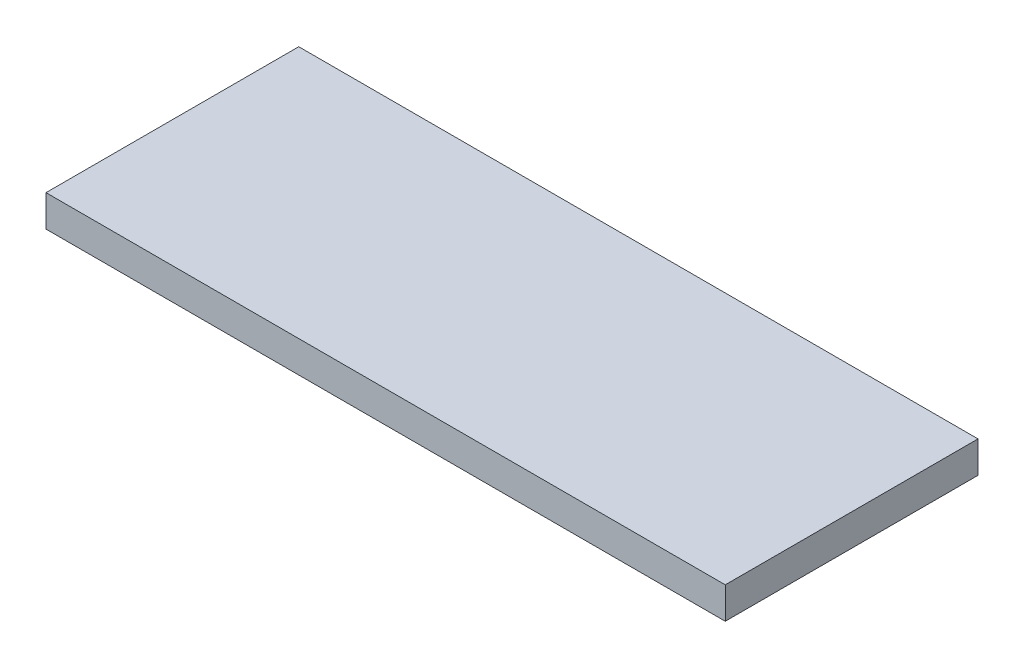
from build123d import *

# Parameters (mm, degrees)
CROQUIS1_W              = 172
CROQUIS1_H              = 64
SALIENTE_EXTRUIR1_DEPTH = 8


with BuildPart() as part:
    # Croquis1 → Saliente-Extruir1 (new body)
    with BuildSketch(Plane(origin=(0, 0, 0), x_dir=(1, 0, 0), z_dir=(0, 1, 0))):
        Rectangle(CROQUIS1_W, CROQUIS1_H)
    extrude(amount=SALIENTE_EXTRUIR1_DEPTH)


solid = part.part
